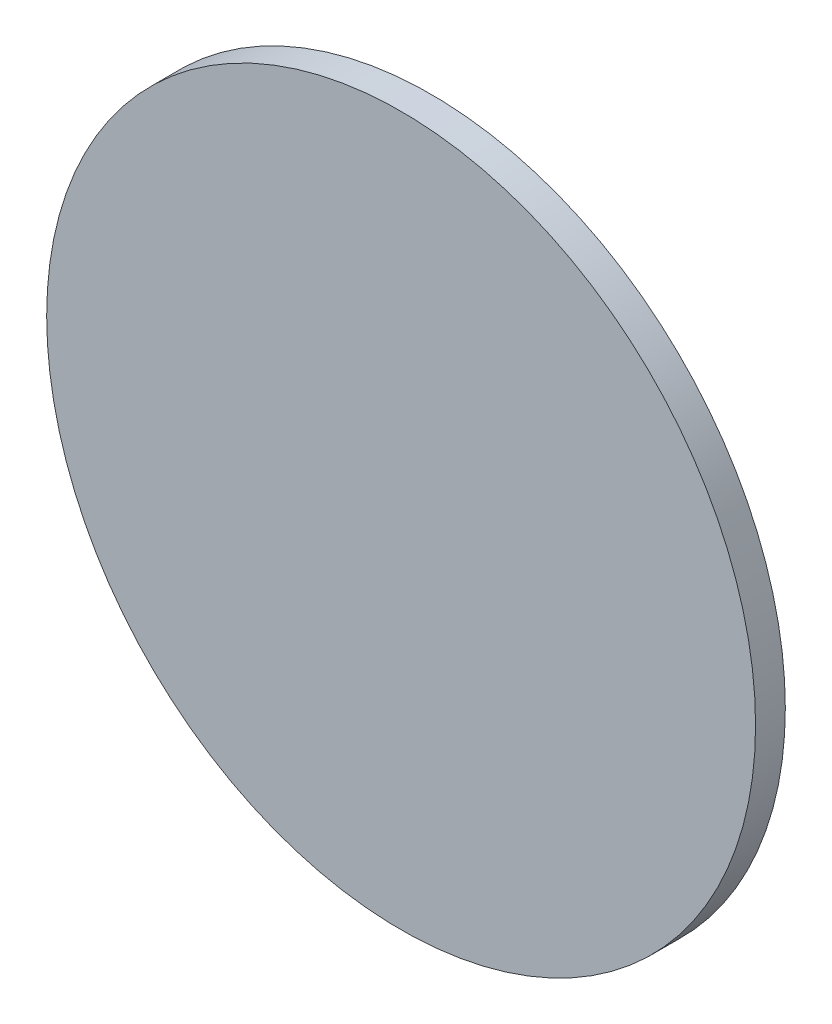
from build123d import *

# Parameters (mm, degrees)
SKETCH_1_R      = 12.5
EXTRUDE_1_DEPTH = 1.05


with BuildPart() as part:
    # 草图1 → 凸台-拉伸1 (new body)
    with BuildSketch(Plane.XY):
        Circle(SKETCH_1_R)
    extrude(amount=EXTRUDE_1_DEPTH)


solid = part.part
